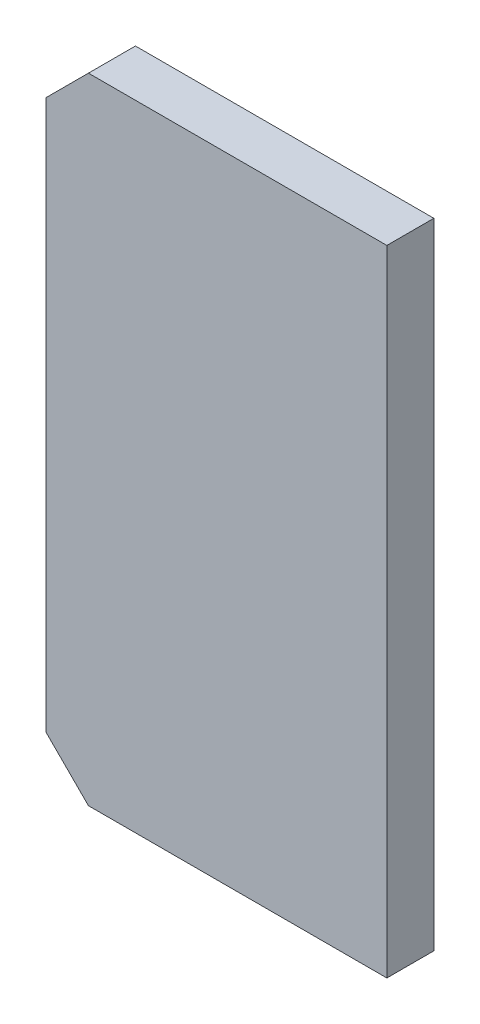
from build123d import *

# Parameters (mm, degrees)
EXTRUDE_1_DEPTH = 20


with BuildPart() as part:
    # Эскиз1 → Бобышка-Вытянуть1 (new body)
    with BuildSketch(Plane.XY):
        Polygon((0, 135), (-127, 135), (-145, 117), (-145, -117), (-127, -135), (0, -135), align=None)
    extrude(amount=EXTRUDE_1_DEPTH)


solid = part.part
